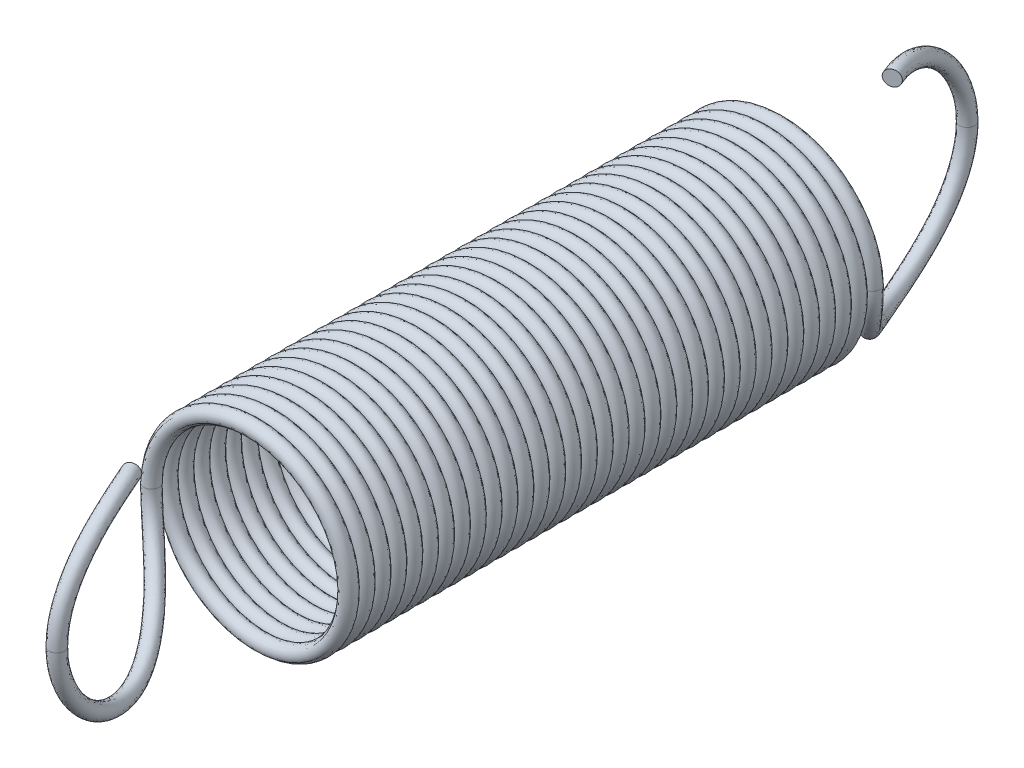
from build123d import *

# Parameters (mm, degrees)
SPRING_BODY_SWEEP_PITCH      = 0.310447761
SPRING_BODY_SWEEP_HEIGHT     = 10.4
SPRING_BODY_SWEEP_RADIUS     = 1.85
SKETCH4_R                    = 0.15
SKETCH7_R                    = 0.15
SPRING_HOOK_CIRPATTERN_COUNT = 2


with BuildPart() as part:
    # Spring Body Sweep: sweep along a helix
    with BuildLine() as spring_body_sweep_path:
        Helix(SPRING_BODY_SWEEP_PITCH, SPRING_BODY_SWEEP_HEIGHT, SPRING_BODY_SWEEP_RADIUS, center=(0, 0, 5.2), direction=(0, 0, -1))
    # Sketch4 → Spring Body Sweep (sweep)
    with BuildSketch(Plane(origin=(0, 0, 0), x_dir=(1, 0, 0), z_dir=(0, 1, 0))):
        with Locations((-1.85, -5.2)):
            Circle(SKETCH4_R)
    sweep(path=spring_body_sweep_path.line, is_frenet=True)

    # Spring Hook Sweep: sweep along a curve in space
    with BuildLine() as spring_hook_sweep_path:
        add(Edge.make_bspline(
            [(-1.85, 0, 5.2), (-1.85, -0.528140498, 5.2), (-1.550614583, -0.976088233, 5.419988407), (-0.980972011, -1.597724186, 6.021912718), (-0.680442249, -1.805567343, 6.429581119), (-0.229418643, -1.88220383, 7.369846466), (-0.093516706, -1.72357453, 7.896666392), (0.010292431, -1.038437907, 8.665301783), (0, -0.525139218, 8.9), (0, 0, 8.9)],
            knots=[0, 0, 0, 0, 0.25, 0.25, 0.5, 0.5, 0.75, 0.75, 1, 1, 1, 1], degree=3))
        add(Edge.make_bspline(
            [(0, 0, 8.9), (0, 0.497124297, 8.9), (0.008715354, 0.984915526, 8.690551094), (-0.076719259, 1.666764272, 7.989874112), (-0.187400538, 1.85, 7.50531772), (-0.386117482, 1.85, 7.05)],
            knots=[0, 0, 0, 0, 0.5, 0.5, 1, 1, 1, 1], degree=3))
    # Sketch7 → Spring Hook Sweep (sweep)
    with BuildSketch(Plane.XZ):
        with Locations((-1.85, 5.2)):
            Circle(SKETCH7_R)
    spring_hook_sweep = sweep(path=spring_hook_sweep_path.line)

    # Spring Hook CirPattern: Spring Hook Sweep ×2 about axis
    spring_hook_cirpattern_axis = Axis((0, 2.540341184, 0), (0, -1, 0))
    for i in range(1, SPRING_HOOK_CIRPATTERN_COUNT):
        add(spring_hook_sweep.rotate(spring_hook_cirpattern_axis, i * 360 / SPRING_HOOK_CIRPATTERN_COUNT))


solid = part.part
